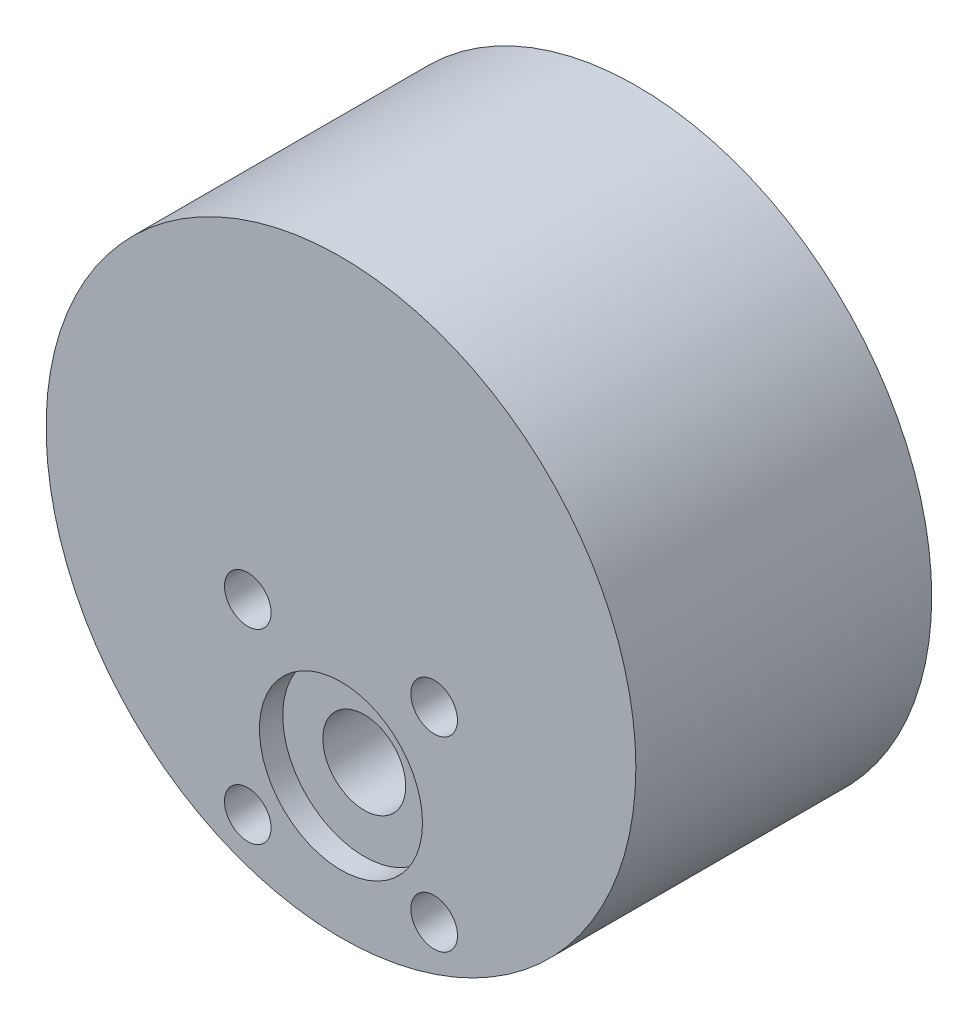
from build123d import *

# Parameters (mm, degrees)
SKETCH1_R           = 25.314646171
BOSS_EXTRUDE1_DEPTH = 25.4
SKETCH2_R           = 3.556
CUT_EXTRUDE1_DEPTH  = 25.4
SKETCH3_R           = 7
SKETCH3_R_2         = 3.556
CUT_EXTRUDE2_DEPTH  = 2
SKETCH4_R           = 2
CUT_EXTRUDE3_DEPTH  = 26.4


with BuildPart() as part:
    # Sketch1 → Boss-Extrude1 (new body)
    with BuildSketch(Plane.XY):
        Circle(SKETCH1_R)
    extrude(amount=BOSS_EXTRUDE1_DEPTH)

    # Sketch2 → Cut-Extrude1 (cut)
    with BuildSketch(Plane.XY.offset(25.4)):
        with Locations((0, -13.278788033)):
            Circle(SKETCH2_R)
    extrude(amount=-CUT_EXTRUDE1_DEPTH, mode=Mode.SUBTRACT)

    # Sketch3 → Cut-Extrude2 (cut)
    with BuildSketch(Plane.XY.offset(25.4)):
        with Locations((0, -13.278788033)):
            Circle(SKETCH3_R)
        with Locations((0, -13.278788033)):
            Circle(SKETCH3_R_2, mode=Mode.SUBTRACT)
    extrude(amount=-CUT_EXTRUDE2_DEPTH, mode=Mode.SUBTRACT)

    # Sketch4 → Cut-Extrude3 (cut, through all)
    with BuildSketch(Plane.XY.offset(25.4)):
        with Locations((-8, -4.158160147)):
            Circle(SKETCH4_R)
        with Locations((8, -4.158160147)):
            Circle(SKETCH4_R)
        with Locations((8, -20.158160147)):
            Circle(SKETCH4_R)
        with Locations((-8, -20.158160147)):
            Circle(SKETCH4_R)
    extrude(amount=-CUT_EXTRUDE3_DEPTH, mode=Mode.SUBTRACT)


solid = part.part
